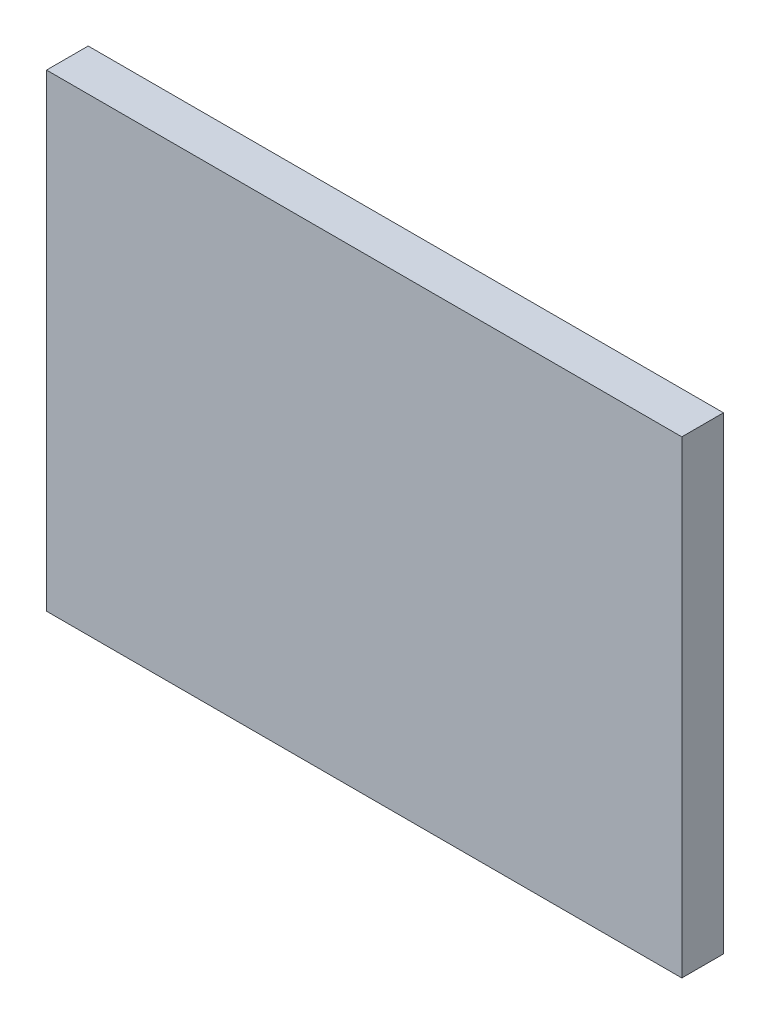
from build123d import *

# Parameters (mm, degrees)
SKETCH1_W           = 61
SKETCH1_H           = 45
BOSS_EXTRUDE1_DEPTH = 4


with BuildPart() as part:
    # Sketch1 → Boss-Extrude1 (new body)
    with BuildSketch(Plane.XY):
        with Locations((30.5, 22.5)):
            Rectangle(SKETCH1_W, SKETCH1_H)
    extrude(amount=BOSS_EXTRUDE1_DEPTH)


solid = part.part
